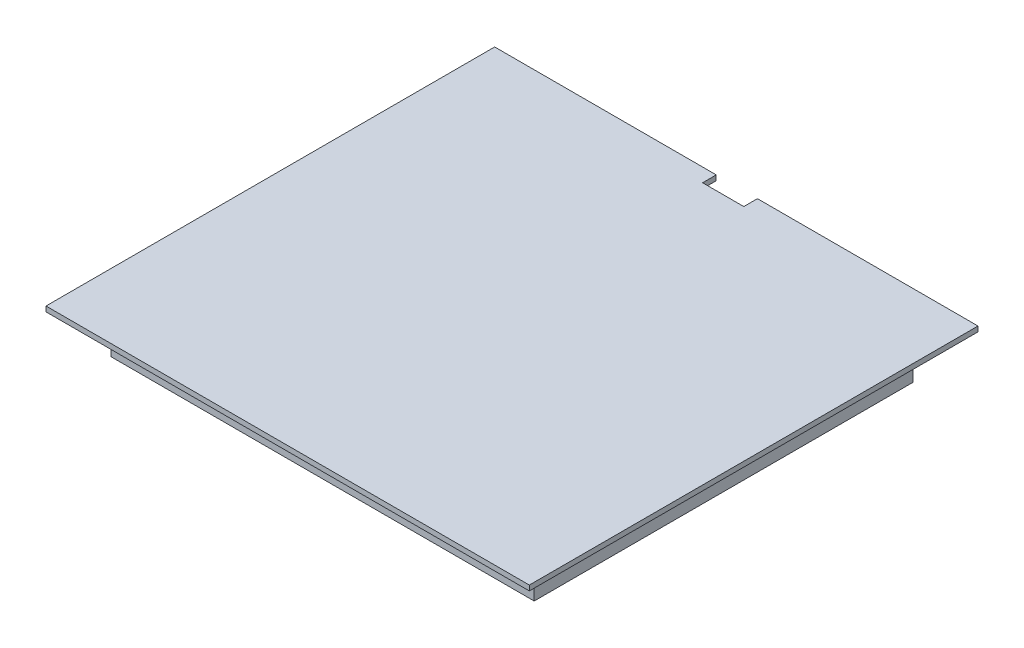
from build123d import *

# Parameters (mm, degrees)
SKETCH1_W           = 74.422
SKETCH1_H           = 69.088
BOSS_EXTRUDE1_DEPTH = 0.7874
SKETCH2_W           = 65.16654669
SKETCH2_H           = 58.334735
BOSS_EXTRUDE2_DEPTH = 6.35
SKETCH3_W           = 6.344505944
SKETCH3_H           = 2.10385028
CUT_EXTRUDE1_DEPTH  = 6.35


with BuildPart() as part:
    # Sketch1 → Boss-Extrude1 (new body)
    with BuildSketch(Plane(origin=(0, 0, 0), x_dir=(1, 0, 0), z_dir=(0, 1, 0))):
        Rectangle(SKETCH1_W, SKETCH1_H)
    extrude(amount=BOSS_EXTRUDE1_DEPTH)

    # Sketch3 → Cut-Extrude1 (cut)
    with BuildSketch(Plane(origin=(0, 0.7874, 0), x_dir=(1, 0, 0), z_dir=(0, 1, 0))):
        with Locations((0.078037772, 33.49207486)):
            Rectangle(SKETCH3_W, SKETCH3_H)
    extrude(amount=-CUT_EXTRUDE1_DEPTH, mode=Mode.SUBTRACT)


with BuildPart() as body_2:
    # Sketch2 → Boss-Extrude2 (new body)
    with BuildSketch(Plane.XZ):
        Rectangle(SKETCH2_W, SKETCH2_H)
    extrude(amount=BOSS_EXTRUDE2_DEPTH)


solid = Compound([part.part, body_2.part])
